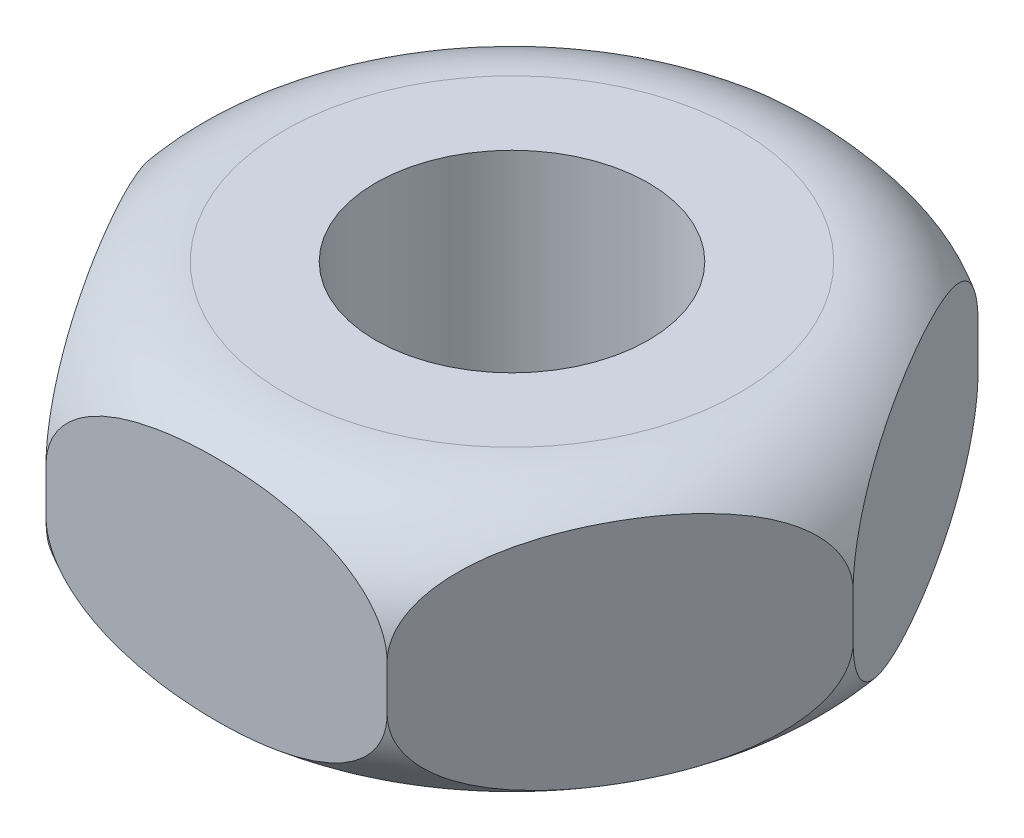
from build123d import *

# Parameters (mm, degrees)
SKETCH1_R           = 6
BOSS_EXTRUDE1_DEPTH = 6


with BuildPart() as part:
    # Sketch1 → Boss-Extrude1 (new body, symmetric)
    with BuildSketch(Plane(origin=(0, 0, 0), x_dir=(1, 0, 0), z_dir=(0, 1, 0))):
        Polygon((15.011106999, 0), (7.505553499, 13), (-7.505553499, 13), (-15.011106999, 0), (-7.505553499, -13), (7.505553499, -13), align=None)
        Circle(SKETCH1_R, mode=Mode.SUBTRACT)
    extrude(amount=BOSS_EXTRUDE1_DEPTH, both=True)

    # Sketch2 → Cut-Revolve1 (revolve, cut)
    with BuildSketch(Plane.XY):
        with BuildLine():
            Line((15.011106999, 1), (15.011106999, 6))
            Line((15.011106999, 6), (10.011106999, 6))
            ThreePointArc((10.011106999, 6), (13.546640905, 4.535533906), (15.011106999, 1))
        make_face()
    cut_revolve1 = revolve(axis=Axis((0, -5.449559113, 0), (0, 1, 0)), mode=Mode.SUBTRACT)

    # Mirror1: Cut-Revolve1 across plane
    add(cut_revolve1.mirror(Plane.ZX), mode=Mode.SUBTRACT)


solid = part.part
